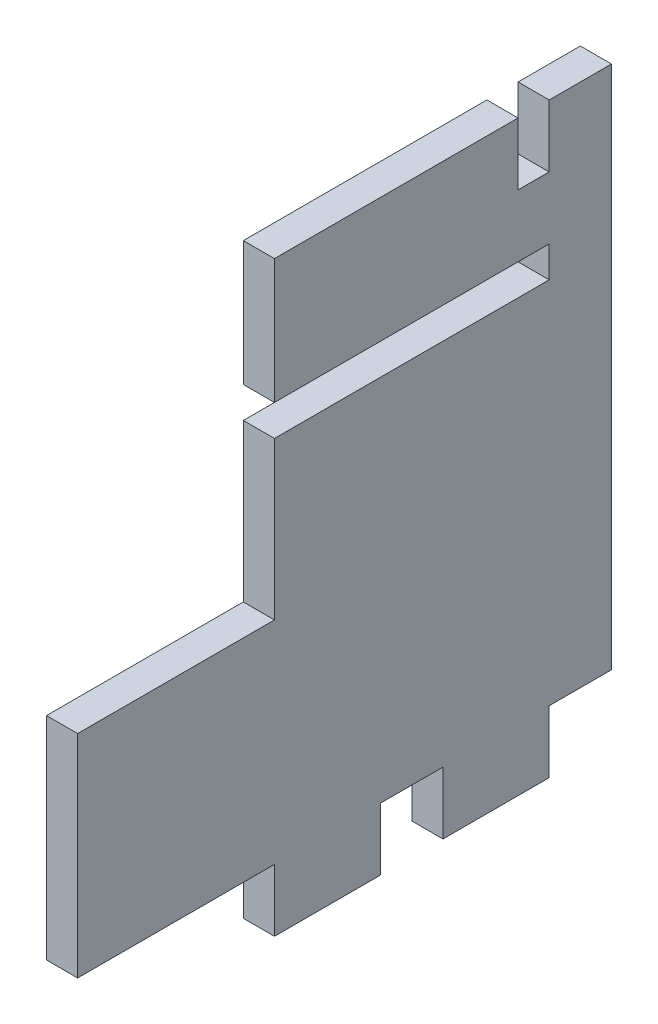
from build123d import *

# Parameters (mm, degrees)
BOSS_EXTRUDE1_DEPTH = 3.175


with BuildPart() as part:
    # Sketch1 → Boss-Extrude1 (new body)
    with BuildSketch(Plane(origin=(0, 0, 0), x_dir=(0, 0, -1), z_dir=(1, 0, 0))):
        Polygon((14, -21.971), (14, -15.621), (20.35, -15.621), (20.35, 37.846), (14, 37.846), (14, 31.496), (10.825, 31.496), (10.825, 37.846), (-14, 37.846), (-14, 25.146), (14, 25.146), (14, 21.971), (-14, 21.971), (-14, 5.954), (-34.058155972, 5.954), (-34.058155972, -15.621), (-14, -15.621), (-14, -21.971), (-3.175, -21.971), (-3.175, -15.621), (3.175, -15.621), (3.175, -21.971), align=None)
    extrude(amount=BOSS_EXTRUDE1_DEPTH)


solid = part.part
